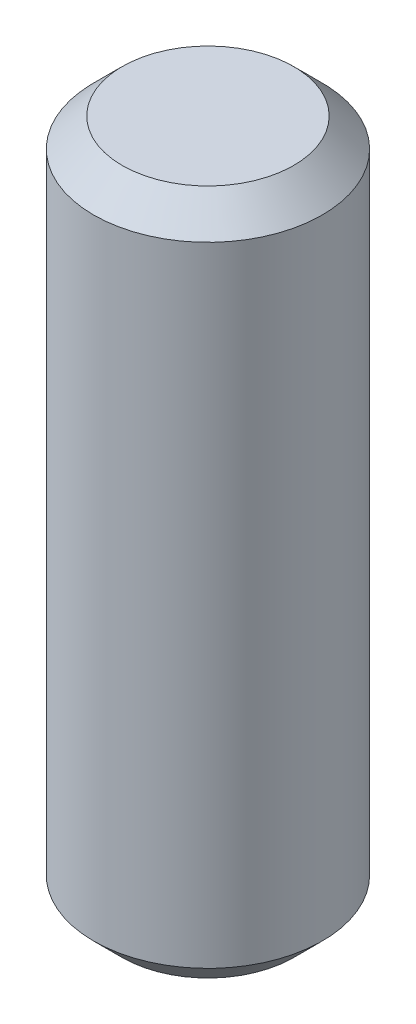
from build123d import *

# Parameters (mm, degrees)
SKETCH2_R           = 1
BOSS_EXTRUDE1_DEPTH = 6
CHAMFER1_SIZE       = 0.25


with BuildPart() as part:
    # Sketch2 → Boss-Extrude1 (new body)
    with BuildSketch(Plane(origin=(0, 0, 0), x_dir=(1, 0, 0), z_dir=(0, 1, 0))):
        Circle(SKETCH2_R)
    extrude(amount=BOSS_EXTRUDE1_DEPTH)

    # Chamfer1
    chamfer1_edges = [part.edges().sort_by_distance(p)[0] for p in [
        (-1, 0, 0),
        (-1, 6, 0),
    ]]
    chamfer(chamfer1_edges, length=CHAMFER1_SIZE)


solid = part.part
